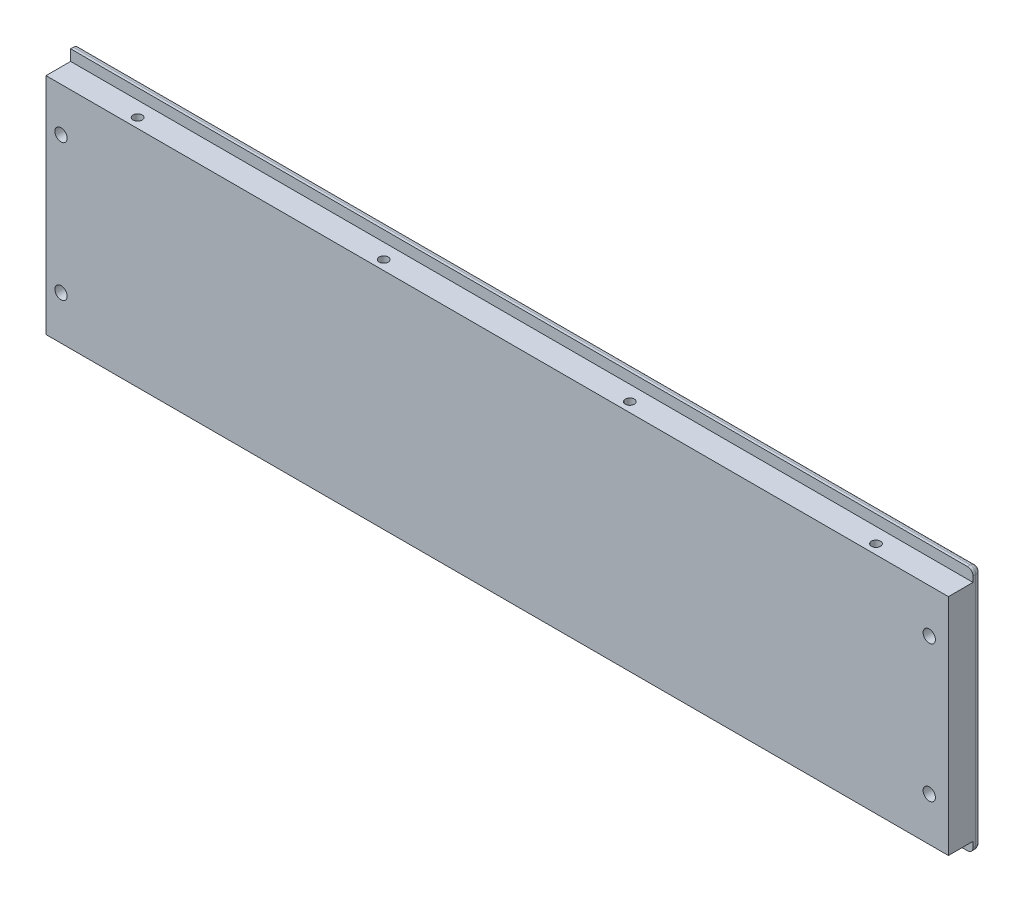
from build123d import *

# Parameters (mm, degrees)
SKETCH_1_W                     = 330
SKETCH_1_H                     = 90
EXTRUDE_1_DEPTH                = 12
SKETCH_2_W                     = 9
SKETCH_2_H                     = 4
CUT_EXTRUDE_1_DEPTH            = 331
FILLET_1_R                     = 2
FILLET_2_R                     = 2
HOLE_WIZARD_M4_1_D             = 3.3
HOLE_WIZARD_M4_1_2_D           = 4.5
HOLE_WIZARD_M4_1_2_CSINK_D     = 9.4
HOLE_WIZARD_M4_1_2_CSINK_ANGLE = 90


with BuildPart() as part:
    # 草圖1 → 填料-伸長1 (new body)
    with BuildSketch(Plane.XY):
        with Locations((165, 45)):
            Rectangle(SKETCH_1_W, SKETCH_1_H)
    extrude(amount=EXTRUDE_1_DEPTH)

    # 草圖2 → 除料-伸長1 (cut, through all)
    with BuildSketch(Plane.ZY):
        with Locations((7.5, 88)):
            Rectangle(SKETCH_2_W, SKETCH_2_H)
        with Locations((7.5, 2)):
            Rectangle(SKETCH_2_W, SKETCH_2_H)
    extrude(amount=-CUT_EXTRUDE_1_DEPTH, mode=Mode.SUBTRACT)

    # 圓角1
    fillet_1_edges = [part.edges().sort_by_distance(p)[0] for p in [
        (165, 90, 0),
        (165, 0, 0),
    ]]
    fillet(fillet_1_edges, radius=FILLET_1_R)

    # 圓角2
    fillet_2_edges = [part.edges().sort_by_distance(p)[0] for p in [
        (330, 90, 2.5),
        (330, 0, 2.5),
        (330, 45, 0),
        (330, 89.414213562, 0.585786438),
        (330, 0.585786438, 0.585786438),
    ]]
    fillet(fillet_2_edges, radius=FILLET_2_R)

    # Hole Wizard M4 _1 (through all)
    with Locations(Plane(origin=(0, 86, 0), x_dir=(1, 0, 0), z_dir=(0, 1, 0))):
        with Locations((30, -8.5), (120, -8.5), (210, -8.5), (300, -8.5)):
            Hole(HOLE_WIZARD_M4_1_D / 2)

    # Hole Wizard M4 _1 2 (through all)
    with Locations(Plane(origin=(0, 0, 0), x_dir=(-1, 0, 0), z_dir=(0, 0, -1))):
        with Locations((-323, 20), (-323, 70), (-5.5, 20), (-5.5, 70)):
            CounterSinkHole(HOLE_WIZARD_M4_1_2_D / 2, HOLE_WIZARD_M4_1_2_CSINK_D / 2, counter_sink_angle=HOLE_WIZARD_M4_1_2_CSINK_ANGLE)


solid = part.part
